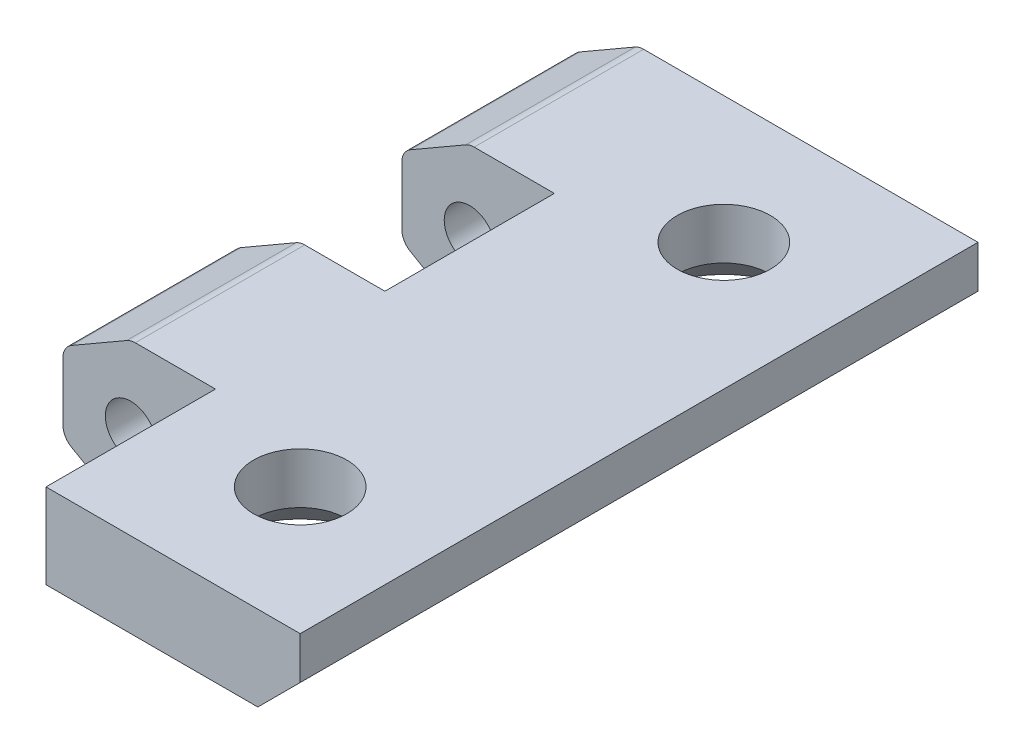
from build123d import *

# Parameters (mm, degrees)
SKETCH1_R      = 1.5
EXTRUDE1_DEPTH = 40
SKETCH2_R      = 2.75
EXTRUDE2_DEPTH = 10
CHAMFER1_SIZE  = 2
SKETCH3_W      = 12.733635698
SKETCH3_H      = 10
SKETCH3_W_2    = 13.399455213
EXTRUDE3_DEPTH = 10
FILLET1_R      = 1


with BuildPart() as part:
    # Sketch1 → Extrude1 (new body)
    with BuildSketch(Plane.XY):
        Polygon((4, -0.381197846), (17.5, -0.381197846), (20, 2.118802154), (20, 4.618802154), (0, 4.618802154), (-4, 2.309401077), (-4, -2.309401077), (0, -4.618802154), (4, -2.309401077), align=None)
        Circle(SKETCH1_R, mode=Mode.SUBTRACT)
    extrude(amount=EXTRUDE1_DEPTH)

    # Sketch2 → Extrude2 (cut)
    with BuildSketch(Plane.XZ.offset(0.381197846)):
        with Locations((12.5, 32.5)):
            Circle(SKETCH2_R)
        with Locations((12.5, 7.5)):
            Circle(SKETCH2_R)
    extrude(amount=-EXTRUDE2_DEPTH, mode=Mode.SUBTRACT)

    # Chamfer1
    chamfer1_edges = [part.edges().sort_by_distance(p)[0] for p in [
        (9.75, -0.381197846, 32.5),
        (9.75, -0.381197846, 7.5),
    ]]
    chamfer(chamfer1_edges, length=CHAMFER1_SIZE)

    # Sketch3 → Extrude3 (cut)
    with BuildSketch(Plane(origin=(0, 4.618802154, 0), x_dir=(1, 0, 0), z_dir=(0, 1, 0))):
        with Locations((-1.366817849, -35)):
            Rectangle(SKETCH3_W, SKETCH3_H)
        with Locations((-1.699727607, -15)):
            Rectangle(SKETCH3_W_2, SKETCH3_H)
    extrude(amount=-EXTRUDE3_DEPTH, mode=Mode.SUBTRACT)

    # Fillet1
    fillet1_edges = [part.edges().sort_by_distance(p)[0] for p in [
        (4, -2.309401077, 25),
        (4, -2.309401077, 5),
        (0, -4.618802154, 25),
        (0, -4.618802154, 5),
        (-4, -2.309401077, 25),
        (-4, -2.309401077, 5),
        (-4, 2.309401077, 25),
        (-4, 2.309401077, 5),
        (0, 4.618802154, 25),
        (0, 4.618802154, 5),
    ]]
    fillet(fillet1_edges, radius=FILLET1_R)


solid = part.part
